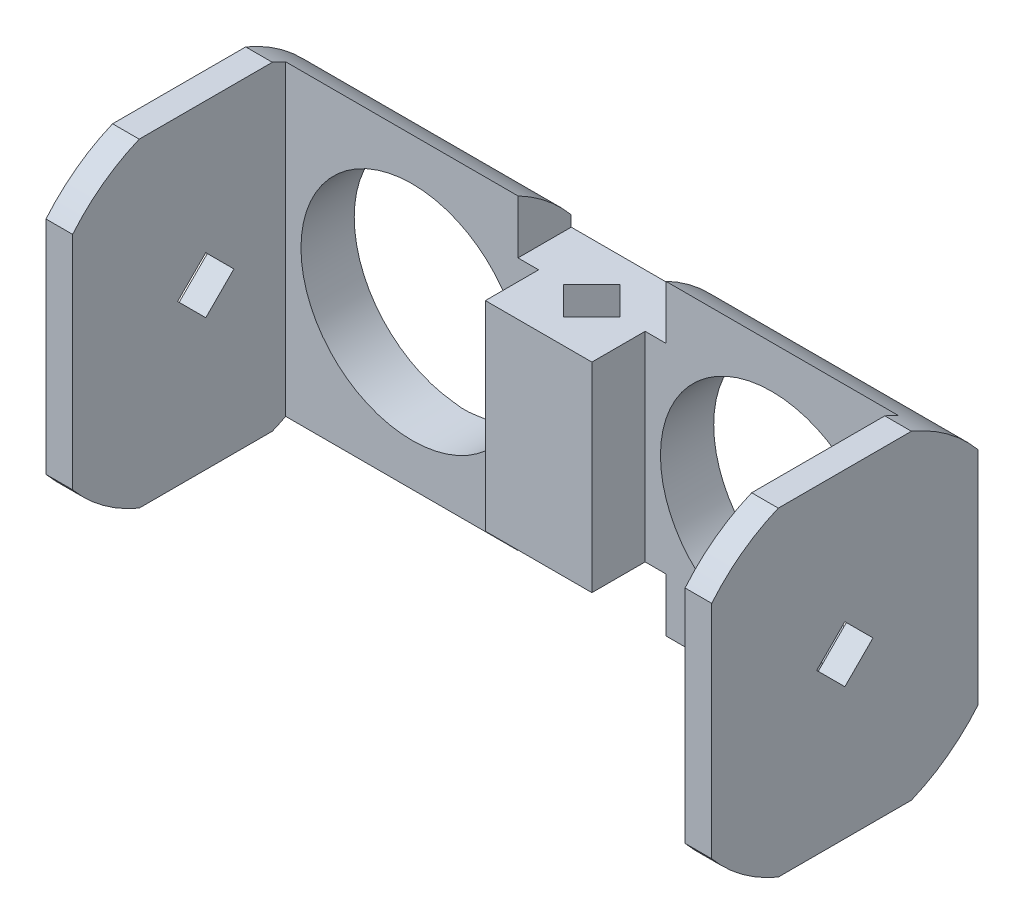
from build123d import *

# Parameters (mm, degrees)
MODEL_R                  = 8.35
RESSALTO_EXTRUS_O2_DEPTH = 4
ESBO_O5_W                = 2
ESBO_O5_H                = 24
RESSALTO_EXTRUS_O3_DEPTH = 20
ESBO_O6_OUTSIDE_W        = 30.002
ESBO_O6_OUTSIDE_H        = 34.002
ESBO_O6_OUTSIDE_R        = 13
CORTE_EXTRUS_O1_DEPTH    = 26
CORTE_EXTRUS_O2_DEPTH    = 26
RESSALTO_EXTRUS_O4_DEPTH = 4
CORTE_EXTRUS_O3_DEPTH    = 20.5000001


with BuildPart() as part:
    # Model → Ressalto-extrusão2 (new body)
    with BuildSketch(Plane.XY):
        Polygon((0, 44.200000002), (0, 59.200000002), (-5.55, 59.200000002), (-5.55, 63.700000002), (-23, 63.700000002), (-23, 39.700000002), (-5.55, 39.700000002), (-5.55, 44.200000002), align=None)
        with Locations((-13.5, 51.700000002)):
            Circle(MODEL_R, mode=Mode.SUBTRACT)
    extrude(amount=RESSALTO_EXTRUS_O2_DEPTH)

    # Esboço5 → Ressalto-extrusão3 (add)
    with BuildSketch(Plane(origin=(0, 0, 0), x_dir=(-1, 0, 0), z_dir=(0, 0, -1))):
        with Locations((24, 51.700000002)):
            Rectangle(ESBO_O5_W, ESBO_O5_H)
    extrude(amount=-RESSALTO_EXTRUS_O3_DEPTH)

    # Esboço6 outside → Corte-extrusão1 (cut, through all)
    with BuildSketch(Plane.ZY.offset(25)):
        with Locations((10, 51.7)):
            Rectangle(ESBO_O6_OUTSIDE_W, ESBO_O6_OUTSIDE_H)
        with Locations((10, 51.700000002)):
            Circle(ESBO_O6_OUTSIDE_R, mode=Mode.SUBTRACT)
    extrude(amount=-CORTE_EXTRUS_O1_DEPTH, mode=Mode.SUBTRACT)

    # Esboço8 → Corte-extrusão2 (cut, through all)
    with BuildSketch(Plane.ZY.offset(25)):
        Polygon((7.885, 51.700000002), (10, 49.585000002), (12.115, 51.700000002), (10, 53.815000002), align=None)
    extrude(amount=-CORTE_EXTRUS_O2_DEPTH, mode=Mode.SUBTRACT)

    # Espelhar1: part across plane


with BuildPart() as part_1:
    add(part.part)
    add(part.part.mirror(Plane(origin=(0, 44.200000002, 4), x_dir=(0, 0, 1), z_dir=(-1, 0, 0))))

    # Esboço9 → Ressalto-extrusão4 (add)
    with BuildSketch(Plane.XY.offset(4)):
        Polygon((0, 59.200000002), (4, 59.200000002), (4, 44.200000002), (-4, 44.200000002), (-4, 59.200000002), align=None)
    extrude(amount=RESSALTO_EXTRUS_O4_DEPTH)

    # Esboço10 → Corte-extrusão3 (cut, through all)
    with BuildSketch(Plane(origin=(0, 59.200000002, 0), x_dir=(1, 0, 0), z_dir=(0, 1, 0))):
        Polygon((0, -1.885), (-2.115, -4), (0, -6.115), (2.115, -4), align=None)
    extrude(amount=-CORTE_EXTRUS_O3_DEPTH, mode=Mode.SUBTRACT)


solid = part_1.part
